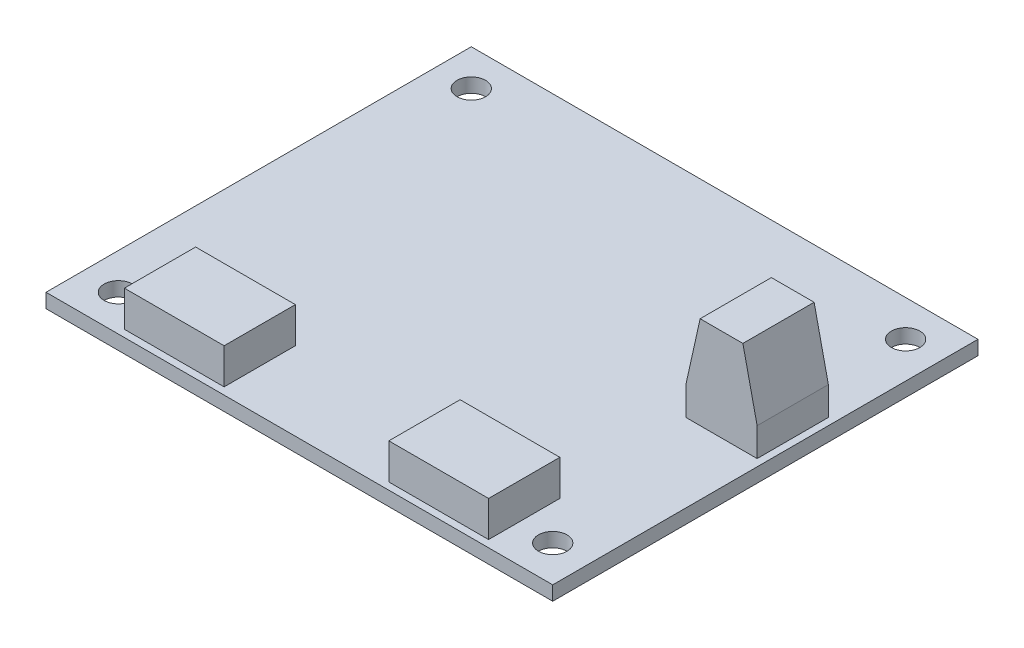
from build123d import *

# Parameters (mm, degrees)
SKETCH1_W           = 71.12
SKETCH1_H           = 59.69
BOSS_EXTRUDE1_DEPTH = 2
SKETCH2_R           = 2
CUT_EXTRUDE1_DEPTH  = 2
SKETCH3_W           = 14
SKETCH3_H           = 10
BOSS_EXTRUDE2_DEPTH = 5
SKETCH4_W           = 10
SKETCH4_H           = 10
BOSS_EXTRUDE3_DEPTH = 13
CUT_EXTRUDE2_DEPTH  = 31


with BuildPart() as part:
    # Sketch1 → Boss-Extrude1 (new body)
    with BuildSketch(Plane(origin=(0, 0, 0), x_dir=(1, 0, 0), z_dir=(0, 1, 0))):
        Rectangle(SKETCH1_W, SKETCH1_H)
    extrude(amount=BOSS_EXTRUDE1_DEPTH)

    # Sketch2 → Cut-Extrude1 (cut)
    with BuildSketch(Plane(origin=(0, 2, 0), x_dir=(1, 0, 0), z_dir=(0, 1, 0))):
        with Locations((-30.48, 24.765)):
            Circle(SKETCH2_R)
        with Locations((30.48, 24.765)):
            Circle(SKETCH2_R)
        with Locations((30.48, -24.765)):
            Circle(SKETCH2_R)
        with Locations((-30.48, -24.765)):
            Circle(SKETCH2_R)
    extrude(amount=-CUT_EXTRUDE1_DEPTH, mode=Mode.SUBTRACT)

    # Sketch3 → Boss-Extrude2 (add)
    with BuildSketch(Plane(origin=(0, 2, 0), x_dir=(1, 0, 0), z_dir=(0, 1, 0))):
        with Locations((-18.56, -23.845)):
            Rectangle(SKETCH3_W, SKETCH3_H)
        with Locations((18.56, -23.845)):
            Rectangle(SKETCH3_W, SKETCH3_H)
    extrude(amount=BOSS_EXTRUDE2_DEPTH)

    # Sketch4 → Boss-Extrude3 (add)
    with BuildSketch(Plane(origin=(0, 2, 0), x_dir=(1, 0, 0), z_dir=(0, 1, 0))):
        with Locations((29.56, 4.845)):
            Rectangle(SKETCH4_W, SKETCH4_H)
    extrude(amount=BOSS_EXTRUDE3_DEPTH)

    # Sketch7 → Cut-Extrude2 (cut, through all)
    with BuildSketch(Plane.XY.offset(0.155)):
        Polygon((26.56, 15), (24.56, 6), (24.56, 15), align=None)
        Polygon((34.56, 6), (32.56, 15), (34.56, 15), align=None)
    extrude(amount=-CUT_EXTRUDE2_DEPTH, mode=Mode.SUBTRACT)


solid = part.part
